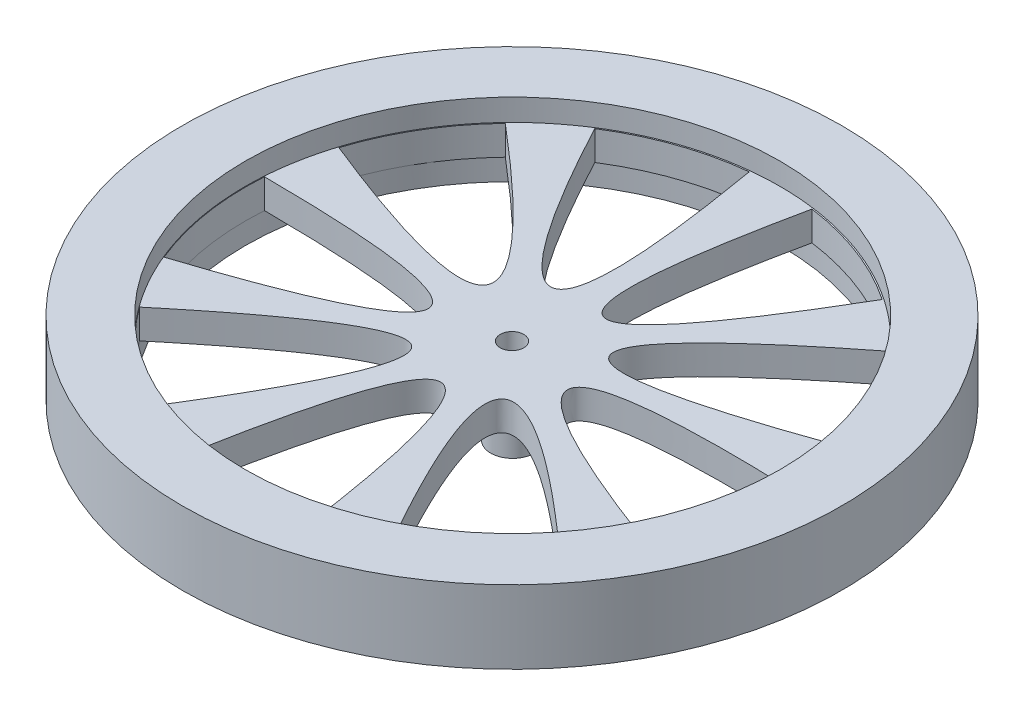
from build123d import *

# Parameters (mm, degrees)
SKETCH1_R                = 45
SKETCH1_R_2              = 1.6
BOSS_EXTRUDE1_DEPTH      = 5
SKETCH4_R                = 36.501480924
CUT_EXTRUDE1_DEPTH       = 3
SKETCH5_R                = 36.501480924
CUT_EXTRUDE2_DEPTH       = 3
SKETCH2_R                = 3
SKETCH2_R_2              = 1.6
BOSS_EXTRUDE2_DEPTH      = 4.8
BOSS_EXTRUDE2_DEPTH_BACK = 4
CUT_EXTRUDE3_DEPTH       = 10
CIRPATTERN1_COUNT        = 9


with BuildPart() as part:
    # Sketch1 → Boss-Extrude1 (new body, symmetric)
    with BuildSketch(Plane(origin=(0, 0, 0), x_dir=(1, 0, 0), z_dir=(0, 1, 0))):
        with Locations((0, -0.088724957)):
            Circle(SKETCH1_R)
        with Locations((0, -0.088724957)):
            Circle(SKETCH1_R_2, mode=Mode.SUBTRACT)
    extrude(amount=BOSS_EXTRUDE1_DEPTH, both=True)

    # Sketch4 → Cut-Extrude1 (cut)
    with BuildSketch(Plane(origin=(0, 5, 0), x_dir=(1, 0, 0), z_dir=(0, 1, 0))):
        Circle(SKETCH4_R)
    extrude(amount=-CUT_EXTRUDE1_DEPTH, mode=Mode.SUBTRACT)

    # Sketch5 → Cut-Extrude2 (cut)
    with BuildSketch(Plane.XZ.offset(5)):
        Circle(SKETCH5_R)
    extrude(amount=-CUT_EXTRUDE2_DEPTH, mode=Mode.SUBTRACT)

    # Sketch2 → Boss-Extrude2 (add, two sides)
    with BuildSketch(Plane.XZ.offset(5)) as boss_extrude2_sk:
        Circle(SKETCH2_R)
        with Locations((0, 0.088724957)):
            Circle(SKETCH2_R_2, mode=Mode.SUBTRACT)
    extrude(amount=BOSS_EXTRUDE2_DEPTH)
    extrude(boss_extrude2_sk.sketch, amount=-BOSS_EXTRUDE2_DEPTH_BACK)

    # Sketch6 → Cut-Extrude3 (cut)
    with BuildSketch(Plane.XZ.offset(2)):
        with BuildLine():
            ThreePointArc((7.771439261, 35.664588059), (-0.52889107, 36.497649018), (-8.801597259, 35.424426535))
            add(Edge.make_bspline(
                [(-8.801597259, 35.424426535), (0.488382971, -15.925400328), (7.771439261, 35.664588059)],
                knots=[0, 0, 0, 1, 1, 1], degree=2))
        make_face()
    cut_extrude3 = extrude(amount=-CUT_EXTRUDE3_DEPTH, mode=Mode.SUBTRACT)

    # CirPattern1: Cut-Extrude3 ×9 about axis
    cirpattern1_axis = Axis((0, 5, 0.088724957), (0, -1, 0))
    for i in range(1, CIRPATTERN1_COUNT):
        add(cut_extrude3.rotate(cirpattern1_axis, i * 360 / CIRPATTERN1_COUNT), mode=Mode.SUBTRACT)


solid = part.part
